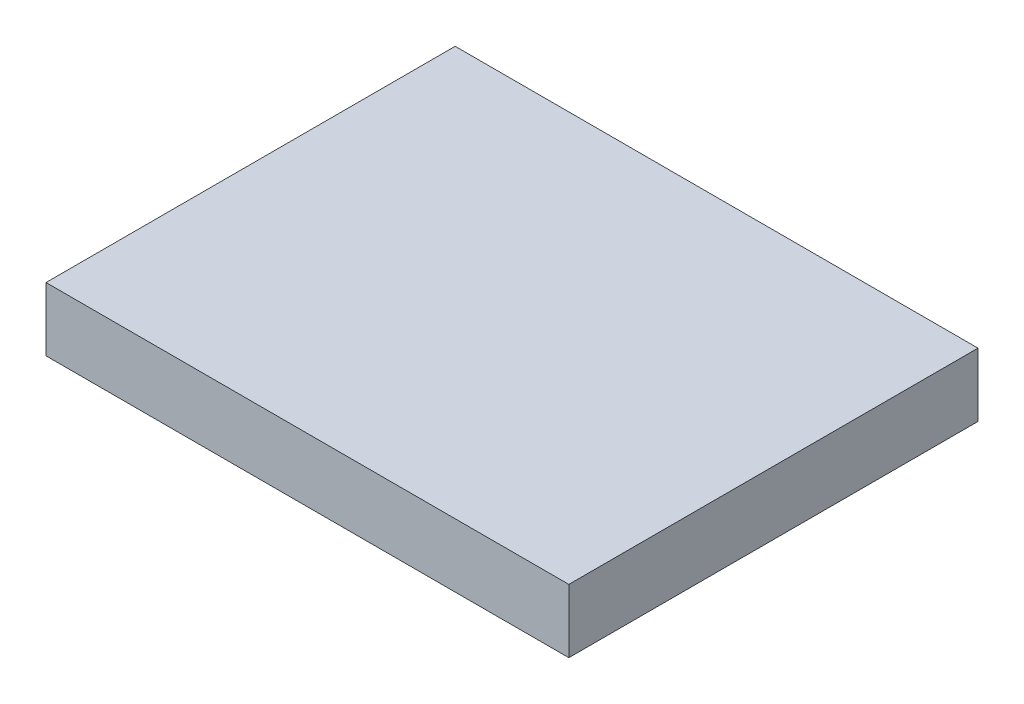
from build123d import *

# Parameters (mm, degrees)
SKETCH1_W           = 69
SKETCH1_H           = 54
BOSS_EXTRUDE1_DEPTH = 8.382


with BuildPart() as part:
    # Sketch1 → Boss-Extrude1 (new body)
    with BuildSketch(Plane(origin=(0, 0, 0), x_dir=(1, 0, 0), z_dir=(0, 1, 0))):
        Rectangle(SKETCH1_W, SKETCH1_H)
    extrude(amount=BOSS_EXTRUDE1_DEPTH)


solid = part.part
